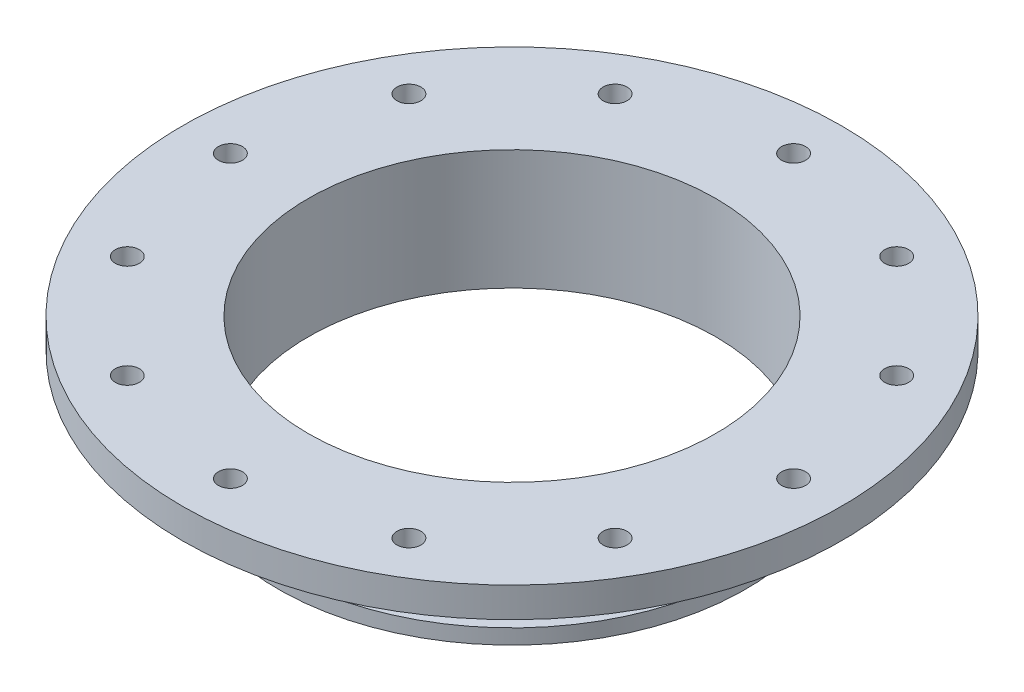
from build123d import *

# Parameters (mm, degrees)
SKETCH1_W           = 26.67
SKETCH1_H           = 6.35
SKETCH2_R           = 49.53
SKETCH2_R_2         = 43.18
BOSS_EXTRUDE1_DEPTH = 19.05
SKETCH3_W           = 3.175
SKETCH3_H           = 2.116666667
SKETCH3_H_2         = 2.116666666
SKETCH4_R           = 2.54
CUT_EXTRUDE1_DEPTH  = 26.4
CIRPATTERN1_COUNT   = 12


with BuildPart() as part:
    # Sketch1 → Revolve1 (revolve)
    with BuildSketch(Plane.XY):
        with Locations((56.515, -3.175)):
            Rectangle(SKETCH1_W, SKETCH1_H)
    revolve(axis=Axis((0, -127, 0), (0, 1, 0)))

    # Sketch2 → Boss-Extrude1 (add)
    with BuildSketch(Plane.XZ.offset(6.35)):
        Circle(SKETCH2_R)
        Circle(SKETCH2_R_2, mode=Mode.SUBTRACT)
    extrude(amount=BOSS_EXTRUDE1_DEPTH)

    # Sketch3 → Cut-Revolve1 (revolve, cut)
    with BuildSketch(Plane.XY):
        with Locations((47.9425, -21.166666666)):
            Rectangle(SKETCH3_W, SKETCH3_H)
        with Locations((47.9425, -15.875)):
            Rectangle(SKETCH3_W, SKETCH3_H_2)
        with Locations((47.9425, -10.583333334)):
            Rectangle(SKETCH3_W, SKETCH3_H)
    revolve(axis=Axis((0, 0, 0), (0, -1, 0)), mode=Mode.SUBTRACT)

    # Sketch4 → Cut-Extrude1 (cut, through all)
    with BuildSketch(Plane(origin=(0, 0, 0), x_dir=(1, 0, 0), z_dir=(0, 1, 0))):
        with Locations((-59.69, 0)):
            Circle(SKETCH4_R)
    cut_extrude1 = extrude(amount=-CUT_EXTRUDE1_DEPTH, mode=Mode.SUBTRACT)

    # CirPattern1: Cut-Extrude1 ×12 about axis
    cirpattern1_axis = Axis((0, 0, 0), (0, 1, 0))
    for i in range(1, CIRPATTERN1_COUNT):
        add(cut_extrude1.rotate(cirpattern1_axis, i * 360 / CIRPATTERN1_COUNT), mode=Mode.SUBTRACT)


solid = part.part
